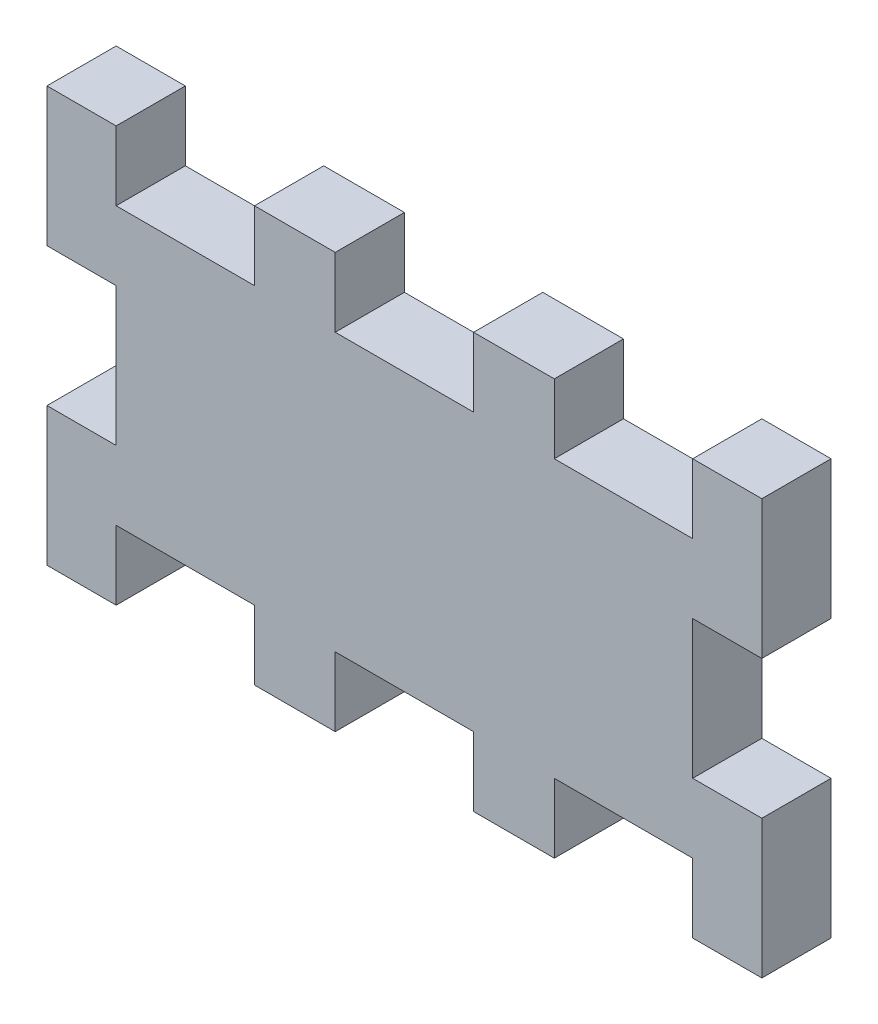
from build123d import *

# Parameters (mm, degrees)
BOSS_EXTRUDE1_DEPTH = 3


with BuildPart() as part:
    # Sketch3 → Boss-Extrude1 (new body)
    with BuildSketch(Plane.XY):
        Polygon((-15.5, 3), (-15.5, 9), (-12.5, 9), (-12.5, 6), (-6.5, 6), (-6.5, 9), (-3, 9), (-3, 6), (3, 6), (3, 9), (6.5, 9), (6.5, 6), (12.5, 6), (12.5, 9), (15.5, 9), (15.5, 3), (12.5, 3), (12.5, -3), (15.5, -3), (15.5, -9), (12.5, -9), (12.5, -6), (6.5, -6), (6.5, -9), (3, -9), (3, -6), (-3, -6), (-3, -9), (-6.5, -9), (-6.5, -6), (-12.5, -6), (-12.5, -9), (-15.5, -9), (-15.5, -3), (-12.5, -3), (-12.5, 3), align=None)
    extrude(amount=BOSS_EXTRUDE1_DEPTH)


solid = part.part
